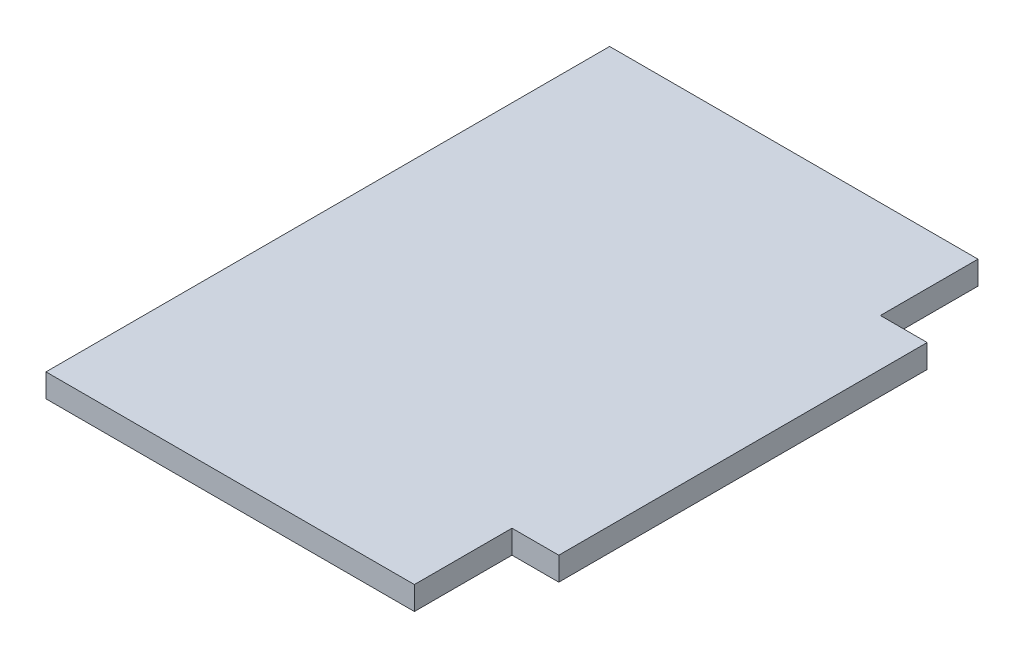
from build123d import *

# Parameters (mm, degrees)
BOSS_EXTRUDE1_DEPTH = 3.175


with BuildPart() as part:
    # Sketch1 → Boss-Extrude1 (new body)
    with BuildSketch(Plane(origin=(0, 0, 0), x_dir=(1, 0, 0), z_dir=(0, 1, 0))):
        Polygon((-25, 0), (-25, 13.25), (25, 13.25), (25, 0), (31.35, 0), (31.35, -50), (25, -50), (25, -63.25), (-25, -63.25), (-25, -50), align=None)
    extrude(amount=BOSS_EXTRUDE1_DEPTH)


solid = part.part
